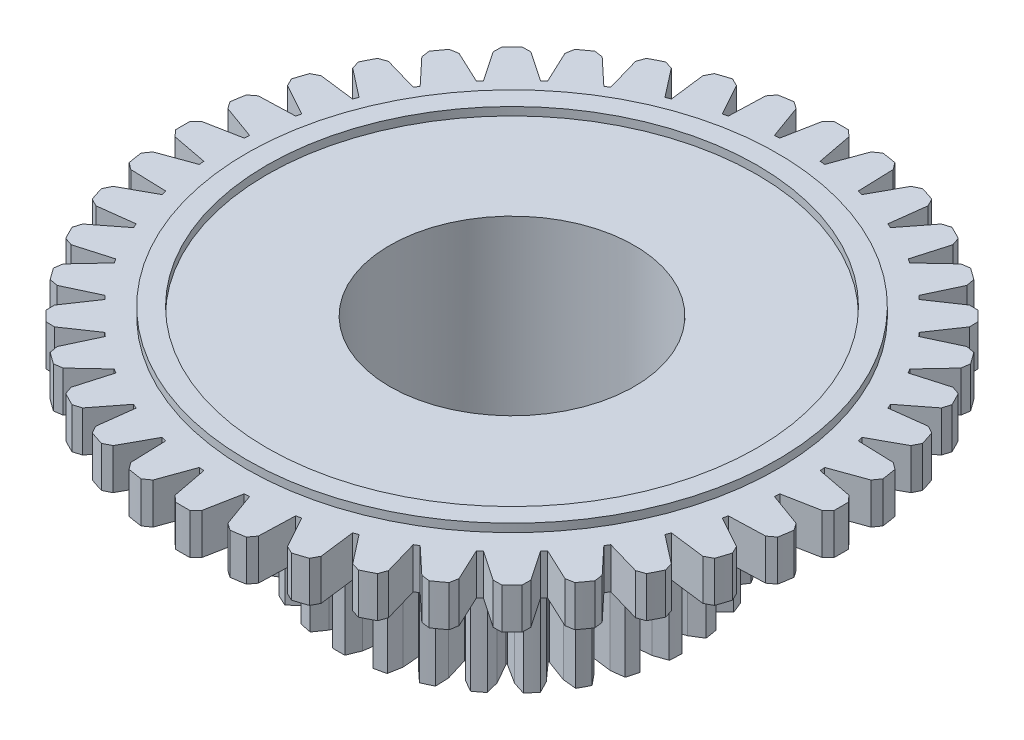
from build123d import *

# Parameters (mm, degrees)
BOSS_EXTRUDE1_DEPTH = 1
SKETCH2_R           = 6.500405198
SKETCH2_R_2         = 6.000405198
BOSS_EXTRUDE2_DEPTH = 0.2
SKETCH4_R           = 2.995
CUT_EXTRUDE3_DEPTH  = 4.2
SKETCH6_R           = 2.995
BOSS_EXTRUDE4_DEPTH = 4


with BuildPart() as part:
    # Sketch1 → Boss-Extrude1 (new body)
    with BuildSketch(Plane(origin=(0, 0, 0), x_dir=(1, 0, 0), z_dir=(0, 1, 0))):
        with BuildLine():
            Line((-0.176242376, 8.068075274), (-0.326242376, 7.922481316))
            Line((-0.326242376, 7.922481316), (-0.493178269, 7.052777835))
            ThreePointArc((-0.493178269, 7.052777835), (-0.554705807, 7.048205549), (-0.616191101, 7.043096516))
            Line((-0.616191101, 7.043096516), (-0.917123335, 7.875977976))
            Line((-0.917123335, 7.875977976), (-1.088052499, 7.996314261))
            ThreePointArc((-1.088052499, 7.996314261), (-1.262426133, 7.970644909), (-1.43619758, 7.941173497))
            Line((-1.43619758, 7.941173497), (-1.561574918, 7.773906872))
            Line((-1.561574918, 7.773906872), (-1.590403954, 6.888796358))
            ThreePointArc((-1.590403954, 6.888796358), (-1.650458722, 6.874655337), (-1.710387802, 6.859990785))
            Line((-1.710387802, 6.859990785), (-2.137906426, 7.635541919))
            Line((-2.137906426, 7.635541919), (-2.325555911, 7.727657453))
            ThreePointArc((-2.325555911, 7.727657453), (-2.493767145, 7.675026087), (-2.660788832, 7.618733674))
            Line((-2.660788832, 7.618733674), (-2.758456302, 7.433913042))
            Line((-2.758456302, 7.433913042), (-2.648468615, 6.555189852))
            ThreePointArc((-2.648468615, 6.555189852), (-2.705571867, 6.531828295), (-2.762469078, 6.507969314))
            Line((-2.762469078, 6.507969314), (-3.306047166, 7.207093479))
            Line((-3.306047166, 7.207093479), (-3.505796418, 7.268720071))
            ThreePointArc((-3.505796418, 7.268720071), (-3.663703333, 7.19042265), (-3.819862633, 7.108695342))
            Line((-3.819862633, 7.108695342), (-3.887415337, 6.910871601))
            Line((-3.887415337, 6.910871601), (-3.64131919, 6.060172816))
            ThreePointArc((-3.64131919, 6.060172816), (-3.694064853, 6.028165962), (-3.746529198, 5.99570004))
            Line((-3.746529198, 5.99570004), (-4.392782052, 6.601182479))
            Line((-4.392782052, 6.601182479), (-4.599712583, 6.630802678))
            ThreePointArc((-4.599712583, 6.630802678), (-4.743426986, 6.528767145), (-4.884878738, 6.423617339))
            Line((-4.884878738, 6.423617339), (-4.920653306, 6.217661565))
            Line((-4.920653306, 6.217661565), (-4.5445084, 5.415934213))
            ThreePointArc((-4.5445084, 5.415934213), (-4.591597702, 5.376070177), (-4.638337335, 5.335796732))
            Line((-4.638337335, 5.335796732), (-5.371352066, 5.832728459))
            Line((-5.371352066, 5.832728459), (-5.580368558, 5.829612917))
            ThreePointArc((-5.580368558, 5.829612917), (-5.706351724, 5.706351724), (-5.829612917, 5.580368558))
            Line((-5.829612917, 5.580368558), (-5.832728459, 5.371352066))
            Line((-5.832728459, 5.371352066), (-5.335796732, 4.638337335))
            ThreePointArc((-5.335796732, 4.638337335), (-5.376070177, 4.591597702), (-5.415934213, 4.5445084))
            Line((-5.415934213, 4.5445084), (-6.217661565, 4.920653306))
            Line((-6.217661565, 4.920653306), (-6.423617339, 4.884878738))
            ThreePointArc((-6.423617339, 4.884878738), (-6.528767145, 4.743426986), (-6.630802678, 4.599712583))
            Line((-6.630802678, 4.599712583), (-6.601182479, 4.392782052))
            Line((-6.601182479, 4.392782052), (-5.99570004, 3.746529198))
            ThreePointArc((-5.99570004, 3.746529198), (-6.028165962, 3.694064853), (-6.060172816, 3.64131919))
            Line((-6.060172816, 3.64131919), (-6.910871601, 3.887415337))
            Line((-6.910871601, 3.887415337), (-7.108695342, 3.819862633))
            ThreePointArc((-7.108695342, 3.819862633), (-7.19042265, 3.663703333), (-7.268720071, 3.505796418))
            Line((-7.268720071, 3.505796418), (-7.207093479, 3.306047166))
            Line((-7.207093479, 3.306047166), (-6.507969314, 2.762469078))
            ThreePointArc((-6.507969314, 2.762469078), (-6.531828295, 2.705571867), (-6.555189852, 2.648468615))
            Line((-6.555189852, 2.648468615), (-7.433913042, 2.758456302))
            Line((-7.433913042, 2.758456302), (-7.618733674, 2.660788832))
            ThreePointArc((-7.618733674, 2.660788832), (-7.675026087, 2.493767145), (-7.727657453, 2.325555911))
            Line((-7.727657453, 2.325555911), (-7.635541919, 2.137906426))
            Line((-7.635541919, 2.137906426), (-6.859990785, 1.710387802))
            ThreePointArc((-6.859990785, 1.710387802), (-6.874655337, 1.650458722), (-6.888796358, 1.590403954))
            Line((-6.888796358, 1.590403954), (-7.773906872, 1.561574918))
            Line((-7.773906872, 1.561574918), (-7.941173497, 1.43619758))
            ThreePointArc((-7.941173497, 1.43619758), (-7.970644909, 1.262426133), (-7.996314261, 1.088052499))
            Line((-7.996314261, 1.088052499), (-7.875977976, 0.917123335))
            Line((-7.875977976, 0.917123335), (-7.043096516, 0.616191101))
            ThreePointArc((-7.043096516, 0.616191101), (-7.048205549, 0.554705807), (-7.052777835, 0.493178269))
            Line((-7.052777835, 0.493178269), (-7.922481316, 0.326242376))
            Line((-7.922481316, 0.326242376), (-8.068075274, 0.176242376))
            ThreePointArc((-8.068075274, 0.176242376), (-8.07, 0), (-8.068075274, -0.176242376))
            Line((-8.068075274, -0.176242376), (-7.922481316, -0.326242376))
            Line((-7.922481316, -0.326242376), (-7.052777835, -0.493178269))
            ThreePointArc((-7.052777835, -0.493178269), (-7.048205549, -0.554705807), (-7.043096516, -0.616191101))
            Line((-7.043096516, -0.616191101), (-7.875977976, -0.917123335))
            Line((-7.875977976, -0.917123335), (-7.996314261, -1.088052499))
            ThreePointArc((-7.996314261, -1.088052499), (-7.970644909, -1.262426133), (-7.941173497, -1.43619758))
            Line((-7.941173497, -1.43619758), (-7.773906872, -1.561574918))
            Line((-7.773906872, -1.561574918), (-6.888796358, -1.590403954))
            ThreePointArc((-6.888796358, -1.590403954), (-6.874655337, -1.650458722), (-6.859990785, -1.710387802))
            Line((-6.859990785, -1.710387802), (-7.635541919, -2.137906426))
            Line((-7.635541919, -2.137906426), (-7.727657453, -2.325555911))
            ThreePointArc((-7.727657453, -2.325555911), (-7.675026087, -2.493767145), (-7.618733674, -2.660788832))
            Line((-7.618733674, -2.660788832), (-7.433913042, -2.758456302))
            Line((-7.433913042, -2.758456302), (-6.555189852, -2.648468615))
            ThreePointArc((-6.555189852, -2.648468615), (-6.531828295, -2.705571867), (-6.507969314, -2.762469078))
            Line((-6.507969314, -2.762469078), (-7.207093479, -3.306047166))
            Line((-7.207093479, -3.306047166), (-7.268720071, -3.505796418))
            ThreePointArc((-7.268720071, -3.505796418), (-7.19042265, -3.663703333), (-7.108695342, -3.819862633))
            Line((-7.108695342, -3.819862633), (-6.910871601, -3.887415337))
            Line((-6.910871601, -3.887415337), (-6.060172816, -3.64131919))
            ThreePointArc((-6.060172816, -3.64131919), (-6.028165962, -3.694064853), (-5.99570004, -3.746529198))
            Line((-5.99570004, -3.746529198), (-6.601182479, -4.392782052))
            Line((-6.601182479, -4.392782052), (-6.630802678, -4.599712583))
            ThreePointArc((-6.630802678, -4.599712583), (-6.528767145, -4.743426986), (-6.423617339, -4.884878738))
            Line((-6.423617339, -4.884878738), (-6.217661565, -4.920653306))
            Line((-6.217661565, -4.920653306), (-5.415934213, -4.5445084))
            ThreePointArc((-5.415934213, -4.5445084), (-5.376070177, -4.591597702), (-5.335796732, -4.638337335))
            Line((-5.335796732, -4.638337335), (-5.832728459, -5.371352066))
            Line((-5.832728459, -5.371352066), (-5.829612917, -5.580368558))
            ThreePointArc((-5.829612917, -5.580368558), (-5.706351724, -5.706351724), (-5.580368558, -5.829612917))
            Line((-5.580368558, -5.829612917), (-5.371352066, -5.832728459))
            Line((-5.371352066, -5.832728459), (-4.638337335, -5.335796732))
            ThreePointArc((-4.638337335, -5.335796732), (-4.591597702, -5.376070177), (-4.5445084, -5.415934213))
            Line((-4.5445084, -5.415934213), (-4.920653306, -6.217661565))
            Line((-4.920653306, -6.217661565), (-4.884878738, -6.423617339))
            ThreePointArc((-4.884878738, -6.423617339), (-4.743426986, -6.528767145), (-4.599712583, -6.630802678))
            Line((-4.599712583, -6.630802678), (-4.392782052, -6.601182479))
            Line((-4.392782052, -6.601182479), (-3.746529198, -5.99570004))
            ThreePointArc((-3.746529198, -5.99570004), (-3.694064853, -6.028165962), (-3.64131919, -6.060172816))
            Line((-3.64131919, -6.060172816), (-3.887415337, -6.910871601))
            Line((-3.887415337, -6.910871601), (-3.819862633, -7.108695342))
            ThreePointArc((-3.819862633, -7.108695342), (-3.663703333, -7.19042265), (-3.505796418, -7.268720071))
            Line((-3.505796418, -7.268720071), (-3.306047166, -7.207093479))
            Line((-3.306047166, -7.207093479), (-2.762469078, -6.507969314))
            ThreePointArc((-2.762469078, -6.507969314), (-2.705571867, -6.531828295), (-2.648468615, -6.555189852))
            Line((-2.648468615, -6.555189852), (-2.758456302, -7.433913042))
            Line((-2.758456302, -7.433913042), (-2.660788832, -7.618733674))
            ThreePointArc((-2.660788832, -7.618733674), (-2.493767145, -7.675026087), (-2.325555911, -7.727657453))
            Line((-2.325555911, -7.727657453), (-2.137906426, -7.635541919))
            Line((-2.137906426, -7.635541919), (-1.710387802, -6.859990785))
            ThreePointArc((-1.710387802, -6.859990785), (-1.650458722, -6.874655337), (-1.590403954, -6.888796358))
            Line((-1.590403954, -6.888796358), (-1.561574918, -7.773906872))
            Line((-1.561574918, -7.773906872), (-1.43619758, -7.941173497))
            ThreePointArc((-1.43619758, -7.941173497), (-1.262426133, -7.970644909), (-1.088052499, -7.996314261))
            Line((-1.088052499, -7.996314261), (-0.917123335, -7.875977976))
            Line((-0.917123335, -7.875977976), (-0.616191101, -7.043096516))
            ThreePointArc((-0.616191101, -7.043096516), (-0.554705807, -7.048205549), (-0.493178269, -7.052777835))
            Line((-0.493178269, -7.052777835), (-0.326242376, -7.922481316))
            Line((-0.326242376, -7.922481316), (-0.176242376, -8.068075274))
            ThreePointArc((-0.176242376, -8.068075274), (0, -8.07), (0.176242376, -8.068075274))
            Line((0.176242376, -8.068075274), (0.326242376, -7.922481316))
            Line((0.326242376, -7.922481316), (0.493178269, -7.052777835))
            ThreePointArc((0.493178269, -7.052777835), (0.554705807, -7.048205549), (0.616191101, -7.043096516))
            Line((0.616191101, -7.043096516), (0.917123335, -7.875977976))
            Line((0.917123335, -7.875977976), (1.088052499, -7.996314261))
            ThreePointArc((1.088052499, -7.996314261), (1.262426133, -7.970644909), (1.43619758, -7.941173497))
            Line((1.43619758, -7.941173497), (1.561574918, -7.773906872))
            Line((1.561574918, -7.773906872), (1.590403954, -6.888796358))
            ThreePointArc((1.590403954, -6.888796358), (1.650458722, -6.874655337), (1.710387802, -6.859990785))
            Line((1.710387802, -6.859990785), (2.137906426, -7.635541919))
            Line((2.137906426, -7.635541919), (2.325555911, -7.727657453))
            ThreePointArc((2.325555911, -7.727657453), (2.493767145, -7.675026087), (2.660788832, -7.618733674))
            Line((2.660788832, -7.618733674), (2.758456302, -7.433913042))
            Line((2.758456302, -7.433913042), (2.648468615, -6.555189852))
            ThreePointArc((2.648468615, -6.555189852), (2.705571867, -6.531828295), (2.762469078, -6.507969314))
            Line((2.762469078, -6.507969314), (3.306047166, -7.207093479))
            Line((3.306047166, -7.207093479), (3.505796418, -7.268720071))
            ThreePointArc((3.505796418, -7.268720071), (3.663703333, -7.19042265), (3.819862633, -7.108695342))
            Line((3.819862633, -7.108695342), (3.887415337, -6.910871601))
            Line((3.887415337, -6.910871601), (3.64131919, -6.060172816))
            ThreePointArc((3.64131919, -6.060172816), (3.694064853, -6.028165962), (3.746529198, -5.99570004))
            Line((3.746529198, -5.99570004), (4.392782052, -6.601182479))
            Line((4.392782052, -6.601182479), (4.599712583, -6.630802678))
            ThreePointArc((4.599712583, -6.630802678), (4.743426986, -6.528767145), (4.884878738, -6.423617339))
            Line((4.884878738, -6.423617339), (4.920653306, -6.217661565))
            Line((4.920653306, -6.217661565), (4.5445084, -5.415934213))
            ThreePointArc((4.5445084, -5.415934213), (4.591597702, -5.376070177), (4.638337335, -5.335796732))
            Line((4.638337335, -5.335796732), (5.371352066, -5.832728459))
            Line((5.371352066, -5.832728459), (5.580368558, -5.829612917))
            ThreePointArc((5.580368558, -5.829612917), (5.706351724, -5.706351724), (5.829612917, -5.580368558))
            Line((5.829612917, -5.580368558), (5.832728459, -5.371352066))
            Line((5.832728459, -5.371352066), (5.335796732, -4.638337335))
            ThreePointArc((5.335796732, -4.638337335), (5.376070177, -4.591597702), (5.415934213, -4.5445084))
            Line((5.415934213, -4.5445084), (6.217661565, -4.920653306))
            Line((6.217661565, -4.920653306), (6.423617339, -4.884878738))
            ThreePointArc((6.423617339, -4.884878738), (6.528767145, -4.743426986), (6.630802678, -4.599712583))
            Line((6.630802678, -4.599712583), (6.601182479, -4.392782052))
            Line((6.601182479, -4.392782052), (5.99570004, -3.746529198))
            ThreePointArc((5.99570004, -3.746529198), (6.028165962, -3.694064853), (6.060172816, -3.64131919))
            Line((6.060172816, -3.64131919), (6.910871601, -3.887415337))
            Line((6.910871601, -3.887415337), (7.108695342, -3.819862633))
            ThreePointArc((7.108695342, -3.819862633), (7.19042265, -3.663703333), (7.268720071, -3.505796418))
            Line((7.268720071, -3.505796418), (7.207093479, -3.306047166))
            Line((7.207093479, -3.306047166), (6.507969314, -2.762469078))
            ThreePointArc((6.507969314, -2.762469078), (6.531828295, -2.705571867), (6.555189852, -2.648468615))
            Line((6.555189852, -2.648468615), (7.433913042, -2.758456302))
            Line((7.433913042, -2.758456302), (7.618733674, -2.660788832))
            ThreePointArc((7.618733674, -2.660788832), (7.675026087, -2.493767145), (7.727657453, -2.325555911))
            Line((7.727657453, -2.325555911), (7.635541919, -2.137906426))
            Line((7.635541919, -2.137906426), (6.859990785, -1.710387802))
            ThreePointArc((6.859990785, -1.710387802), (6.874655337, -1.650458722), (6.888796358, -1.590403954))
            Line((6.888796358, -1.590403954), (7.773906872, -1.561574918))
            Line((7.773906872, -1.561574918), (7.941173497, -1.43619758))
            ThreePointArc((7.941173497, -1.43619758), (7.970644909, -1.262426133), (7.996314261, -1.088052499))
            Line((7.996314261, -1.088052499), (7.875977976, -0.917123335))
            Line((7.875977976, -0.917123335), (7.043096516, -0.616191101))
            ThreePointArc((7.043096516, -0.616191101), (7.048205549, -0.554705807), (7.052777835, -0.493178269))
            Line((7.052777835, -0.493178269), (7.922481316, -0.326242376))
            Line((7.922481316, -0.326242376), (8.068075274, -0.176242376))
            ThreePointArc((8.068075274, -0.176242376), (8.07, 0), (8.068075274, 0.176242376))
            Line((8.068075274, 0.176242376), (7.922481316, 0.326242376))
            Line((7.922481316, 0.326242376), (7.052777835, 0.493178269))
            ThreePointArc((7.052777835, 0.493178269), (7.048205549, 0.554705807), (7.043096516, 0.616191101))
            Line((7.043096516, 0.616191101), (7.875977976, 0.917123335))
            Line((7.875977976, 0.917123335), (7.996314261, 1.088052499))
            ThreePointArc((7.996314261, 1.088052499), (7.970644909, 1.262426133), (7.941173497, 1.43619758))
            Line((7.941173497, 1.43619758), (7.773906872, 1.561574918))
            Line((7.773906872, 1.561574918), (6.888796358, 1.590403954))
            ThreePointArc((6.888796358, 1.590403954), (6.874655337, 1.650458722), (6.859990785, 1.710387802))
            Line((6.859990785, 1.710387802), (7.635541919, 2.137906426))
            Line((7.635541919, 2.137906426), (7.727657453, 2.325555911))
            ThreePointArc((7.727657453, 2.325555911), (7.675026087, 2.493767145), (7.618733674, 2.660788832))
            Line((7.618733674, 2.660788832), (7.433913042, 2.758456302))
            Line((7.433913042, 2.758456302), (6.555189852, 2.648468615))
            ThreePointArc((6.555189852, 2.648468615), (6.531828295, 2.705571867), (6.507969314, 2.762469078))
            Line((6.507969314, 2.762469078), (7.207093479, 3.306047166))
            Line((7.207093479, 3.306047166), (7.268720071, 3.505796418))
            ThreePointArc((7.268720071, 3.505796418), (7.19042265, 3.663703333), (7.108695342, 3.819862633))
            Line((7.108695342, 3.819862633), (6.910871601, 3.887415337))
            Line((6.910871601, 3.887415337), (6.060172816, 3.64131919))
            ThreePointArc((6.060172816, 3.64131919), (6.028165962, 3.694064853), (5.99570004, 3.746529198))
            Line((5.99570004, 3.746529198), (6.601182479, 4.392782052))
            Line((6.601182479, 4.392782052), (6.630802678, 4.599712583))
            ThreePointArc((6.630802678, 4.599712583), (6.528767145, 4.743426986), (6.423617339, 4.884878738))
            Line((6.423617339, 4.884878738), (6.217661565, 4.920653306))
            Line((6.217661565, 4.920653306), (5.415934213, 4.5445084))
            ThreePointArc((5.415934213, 4.5445084), (5.376070177, 4.591597702), (5.335796732, 4.638337335))
            Line((5.335796732, 4.638337335), (5.832728459, 5.371352066))
            Line((5.832728459, 5.371352066), (5.829612917, 5.580368558))
            ThreePointArc((5.829612917, 5.580368558), (5.706351724, 5.706351724), (5.580368558, 5.829612917))
            Line((5.580368558, 5.829612917), (5.371352066, 5.832728459))
            Line((5.371352066, 5.832728459), (4.638337335, 5.335796732))
            ThreePointArc((4.638337335, 5.335796732), (4.591597702, 5.376070177), (4.5445084, 5.415934213))
            Line((4.5445084, 5.415934213), (4.920653306, 6.217661565))
            Line((4.920653306, 6.217661565), (4.884878738, 6.423617339))
            ThreePointArc((4.884878738, 6.423617339), (4.743426986, 6.528767145), (4.599712583, 6.630802678))
            Line((4.599712583, 6.630802678), (4.392782052, 6.601182479))
            Line((4.392782052, 6.601182479), (3.746529198, 5.99570004))
            ThreePointArc((3.746529198, 5.99570004), (3.694064853, 6.028165962), (3.64131919, 6.060172816))
            Line((3.64131919, 6.060172816), (3.887415337, 6.910871601))
            Line((3.887415337, 6.910871601), (3.819862633, 7.108695342))
            ThreePointArc((3.819862633, 7.108695342), (3.663703333, 7.19042265), (3.505796418, 7.268720071))
            Line((3.505796418, 7.268720071), (3.306047166, 7.207093479))
            Line((3.306047166, 7.207093479), (2.762469078, 6.507969314))
            ThreePointArc((2.762469078, 6.507969314), (2.705571867, 6.531828295), (2.648468615, 6.555189852))
            Line((2.648468615, 6.555189852), (2.758456302, 7.433913042))
            Line((2.758456302, 7.433913042), (2.660788832, 7.618733674))
            ThreePointArc((2.660788832, 7.618733674), (2.493767145, 7.675026087), (2.325555911, 7.727657453))
            Line((2.325555911, 7.727657453), (2.137906426, 7.635541919))
            Line((2.137906426, 7.635541919), (1.710387802, 6.859990785))
            ThreePointArc((1.710387802, 6.859990785), (1.650458722, 6.874655337), (1.590403954, 6.888796358))
            Line((1.590403954, 6.888796358), (1.561574918, 7.773906872))
            Line((1.561574918, 7.773906872), (1.43619758, 7.941173497))
            ThreePointArc((1.43619758, 7.941173497), (1.262426133, 7.970644909), (1.088052499, 7.996314261))
            Line((1.088052499, 7.996314261), (0.917123335, 7.875977976))
            Line((0.917123335, 7.875977976), (0.616191101, 7.043096516))
            ThreePointArc((0.616191101, 7.043096516), (0.554705807, 7.048205549), (0.493178269, 7.052777835))
            Line((0.493178269, 7.052777835), (0.326242376, 7.922481316))
            Line((0.326242376, 7.922481316), (0.176242376, 8.068075274))
            ThreePointArc((0.176242376, 8.068075274), (0, 8.07), (-0.176242376, 8.068075274))
        make_face()
    extrude(amount=BOSS_EXTRUDE1_DEPTH)

    # Sketch2 → Boss-Extrude2 (add)
    with BuildSketch(Plane(origin=(0, 1, 0), x_dir=(1, 0, 0), z_dir=(0, 1, 0))):
        Circle(SKETCH2_R)
        Circle(SKETCH2_R_2, mode=Mode.SUBTRACT)
    extrude(amount=BOSS_EXTRUDE2_DEPTH)

    # Sketch4 → Cut-Extrude3 (cut)
    with BuildSketch(Plane(origin=(0, 1, 0), x_dir=(1, 0, 0), z_dir=(0, 1, 0))):
        Circle(SKETCH4_R)
    extrude(amount=-CUT_EXTRUDE3_DEPTH, mode=Mode.SUBTRACT)

    # Sketch6 → Boss-Extrude4 (add)
    with BuildSketch(Plane.XZ):
        with BuildLine():
            Line((0.148148364, 4.242414061), (0.275189289, 3.935390178))
            Line((0.275189289, 3.935390178), (0.354610282, 3.357133897))
            ThreePointArc((0.354610282, 3.357133897), (0.364989316, 3.356021343), (0.375364861, 3.354876701))
            Line((0.375364861, 3.354876701), (0.577237043, 3.902540505))
            Line((0.577237043, 3.902540505), (0.767308881, 4.175076296))
            ThreePointArc((0.767308881, 4.175076296), (0.912549519, 4.145754259), (1.056678355, 4.111381259))
            Line((1.056678355, 4.111381259), (1.114748075, 3.78422538))
            Line((1.114748075, 3.78422538), (1.068004243, 3.202415244))
            ThreePointArc((1.068004243, 3.202415244), (1.077901455, 3.199097515), (1.08778836, 3.195749198))
            Line((1.08778836, 3.195749198), (1.402672412, 3.687212376))
            Line((1.402672412, 3.687212376), (1.646887615, 3.912516605))
            ThreePointArc((1.646887615, 3.912516605), (1.782429236, 3.852657657), (1.915799242, 3.788104838))
            Line((1.915799242, 3.788104838), (1.902182481, 3.456114409))
            Line((1.902182481, 3.456114409), (1.731459512, 2.897955213))
            ThreePointArc((1.731459512, 2.897955213), (1.740412119, 2.892587443), (1.749348085, 2.887192015))
            Line((1.749348085, 2.887192015), (2.162520378, 3.299474294))
            Line((2.162520378, 3.299474294), (2.449459715, 3.467011985))
            ThreePointArc((2.449459715, 3.467011985), (2.568964543, 3.379415064), (2.685339485, 3.287700846))
            Line((2.685339485, 3.287700846), (2.600672947, 2.96639937))
            Line((2.600672947, 2.96639937), (2.313953658, 2.457990017))
            ThreePointArc((2.313953658, 2.457990017), (2.321543046, 2.450823196), (2.329110237, 2.443632943))
            Line((2.329110237, 2.443632943), (2.821251295, 2.757456461))
            Line((2.821251295, 2.757456461), (3.137497801, 2.859393738))
            ThreePointArc((3.137497801, 2.859393738), (3.235377924, 2.748154779), (3.329316238, 2.633567616))
            Line((3.329316238, 2.633567616), (3.177558837, 2.337978793))
            Line((3.177558837, 2.337978793), (2.788249904, 1.90309194))
            ThreePointArc((2.788249904, 1.90309194), (2.794121201, 1.894461181), (2.799965784, 1.885812309))
            Line((2.799965784, 1.885812309), (3.348063636, 2.086503028))
            Line((3.348063636, 2.086503028), (3.678829976, 2.118073418))
            ThreePointArc((3.678829976, 2.118073418), (3.750508629, 1.988393831), (3.817617864, 1.856291691))
            Line((3.817617864, 1.856291691), (3.605865608, 1.600236926))
            Line((3.605865608, 1.600236926), (3.132170682, 1.259207399))
            ThreePointArc((3.132170682, 1.259207399), (3.136049355, 1.249516267), (3.139898042, 1.239813189))
            Line((3.139898042, 1.239813189), (3.718324244, 1.317987033))
            Line((3.718324244, 1.317987033), (4.048144151, 1.27771434))
            ThreePointArc((4.048144151, 1.27771434), (4.090269718, 1.135657797), (4.127411922, 0.99221763))
            Line((4.127411922, 0.99221763), (3.86556611, 0.787669759))
            Line((3.86556611, 0.787669759), (3.329634641, 0.556443719))
            ThreePointArc((3.329634641, 0.556443719), (3.331339325, 0.546145361), (3.333012157, 0.535841781))
            Line((3.333012157, 0.535841781), (3.914720142, 0.487843429))
            Line((3.914720142, 0.487843429), (4.228171604, 0.377610758))
            ThreePointArc((4.228171604, 0.377610758), (4.238774342, 0.229819667), (4.244212786, 0.081748576))
            Line((4.244212786, 0.081748576), (3.944517037, -0.061727971))
            Line((3.944517037, -0.061727971), (3.371408585, -0.172338651))
            ThreePointArc((3.371408585, -0.172338651), (3.370859572, -0.182762695), (3.370278329, -0.193184993))
            Line((3.370278329, -0.193184993), (3.928068077, -0.365111191))
            Line((3.928068077, -0.365111191), (4.210494453, -0.540149483))
            ThreePointArc((4.210494453, -0.540149483), (4.189078588, -0.686764575), (4.162558977, -0.832542951))
            Line((4.162558977, -0.832542951), (3.839026732, -0.908239369))
            Line((3.839026732, -0.908239369), (3.25553921, -0.893062656))
            ThreePointArc((3.25553921, -0.893062656), (3.252762171, -0.903124971), (3.249954032, -0.913178651))
            Line((3.249954032, -0.913178651), (3.757743915, -1.200993618))
            Line((3.757743915, -1.200993618), (3.99593926, -1.432652934))
            ThreePointArc((3.99593926, -1.432652934), (3.943506176, -1.571236469), (3.886268536, -1.707905695))
            Line((3.886268536, -1.707905695), (3.554027803, -1.712282504))
            Line((3.554027803, -1.712282504), (2.98744444, -1.572028045))
            ThreePointArc((2.98744444, -1.572028045), (2.982569227, -1.581258127), (2.977665496, -1.590473091))
            Line((2.977665496, -1.590473091), (3.411711823, -1.980718918))
            Line((3.411711823, -1.980718918), (3.594538389, -2.258167126))
            ThreePointArc((3.594538389, -2.258167126), (3.513539797, -2.382239092), (3.428260498, -2.503408667))
            Line((3.428260498, -2.503408667), (3.102846485, -2.436261212))
            Line((3.102846485, -2.436261212), (2.579660088, -2.177487149))
            ThreePointArc((2.579660088, -2.177487149), (2.57291466, -2.18545341), (2.566144631, -2.193398776))
            Line((2.566144631, -2.193398776), (2.906151879, -2.667828003))
            Line((2.906151879, -2.667828003), (3.025060898, -2.978091934))
            ThreePointArc((3.025060898, -2.978091934), (2.919284203, -3.081850863), (2.80995081, -3.181855032))
            Line((2.80995081, -3.181855032), (2.506579513, -3.046323053))
            Line((2.506579513, -3.046323053), (2.051253698, -2.681129374))
            ThreePointArc((2.051253698, -2.681129374), (2.042953463, -2.687459321), (2.034633695, -2.693763572))
            Line((2.034633695, -2.693763572), (2.264703503, -3.230192416))
            Line((2.264703503, -3.230192416), (2.314134921, -3.558764472))
            ThreePointArc((2.314134921, -3.558764472), (2.188526124, -3.637358713), (2.060250944, -3.711521392))
            Line((2.060250944, -3.711521392), (1.793107669, -3.513942215))
            Line((1.793107669, -3.513942215), (1.426932965, -3.05940497))
            ThreePointArc((1.426932965, -3.05940497), (1.417466033, -3.063802621), (1.407985549, -3.068170978))
            Line((1.407985549, -3.068170978), (1.517360108, -3.641516621))
            Line((1.517360108, -3.641516621), (1.495002568, -3.973033139))
            ThreePointArc((1.495002568, -3.973033139), (1.355434995, -4.022787712), (1.214216035, -4.067641137))
            Line((1.214216035, -4.067641137), (0.995792103, -3.817253343))
            Line((0.995792103, -3.817253343), (0.735890432, -3.294626189))
            ThreePointArc((0.735890432, -3.294626189), (0.725699467, -3.296885915), (0.715501563, -3.299114119))
            Line((0.715501563, -3.299114119), (0.699066641, -3.882567557))
            Line((0.699066641, -3.882567557), (0.605965555, -4.201527192))
            ThreePointArc((0.605965555, -4.201527192), (0.458965233, -4.220115628), (0.311405733, -4.233562503))
            Line((0.311405733, -4.233562503), (0.151914406, -3.942073948))
            Line((0.151914406, -3.942073948), (0.01043848, -3.37579435))
            ThreePointArc((0.01043848, -3.37579435), (0, -3.375810489), (-0.01043848, -3.37579435))
            Line((-0.01043848, -3.37579435), (-0.151914406, -3.942073948))
            Line((-0.151914406, -3.942073948), (-0.311405733, -4.233562503))
            ThreePointArc((-0.311405733, -4.233562503), (-0.458965233, -4.220115628), (-0.605965555, -4.201527192))
            Line((-0.605965555, -4.201527192), (-0.699066641, -3.882567557))
            Line((-0.699066641, -3.882567557), (-0.715501563, -3.299114119))
            ThreePointArc((-0.715501563, -3.299114119), (-0.725699467, -3.296885915), (-0.735890432, -3.294626189))
            Line((-0.735890432, -3.294626189), (-0.995792103, -3.817253343))
            Line((-0.995792103, -3.817253343), (-1.214216035, -4.067641137))
            ThreePointArc((-1.214216035, -4.067641137), (-1.355434995, -4.022787712), (-1.495002568, -3.973033139))
            Line((-1.495002568, -3.973033139), (-1.517360108, -3.641516621))
            Line((-1.517360108, -3.641516621), (-1.407985549, -3.068170978))
            ThreePointArc((-1.407985549, -3.068170978), (-1.417466033, -3.063802621), (-1.426932965, -3.05940497))
            Line((-1.426932965, -3.05940497), (-1.793107669, -3.513942215))
            Line((-1.793107669, -3.513942215), (-2.060250944, -3.711521392))
            ThreePointArc((-2.060250944, -3.711521392), (-2.188526124, -3.637358713), (-2.314134921, -3.558764472))
            Line((-2.314134921, -3.558764472), (-2.264703503, -3.230192416))
            Line((-2.264703503, -3.230192416), (-2.034633695, -2.693763572))
            ThreePointArc((-2.034633695, -2.693763572), (-2.042953463, -2.687459321), (-2.051253698, -2.681129374))
            Line((-2.051253698, -2.681129374), (-2.506579513, -3.046323053))
            Line((-2.506579513, -3.046323053), (-2.80995081, -3.181855032))
            ThreePointArc((-2.80995081, -3.181855032), (-2.919284203, -3.081850863), (-3.025060898, -2.978091934))
            Line((-3.025060898, -2.978091934), (-2.906151879, -2.667828003))
            Line((-2.906151879, -2.667828003), (-2.566144631, -2.193398776))
            ThreePointArc((-2.566144631, -2.193398776), (-2.57291466, -2.18545341), (-2.579660088, -2.177487149))
            Line((-2.579660088, -2.177487149), (-3.102846485, -2.436261212))
            Line((-3.102846485, -2.436261212), (-3.428260498, -2.503408667))
            ThreePointArc((-3.428260498, -2.503408667), (-3.513539797, -2.382239092), (-3.594538389, -2.258167126))
            Line((-3.594538389, -2.258167126), (-3.411711823, -1.980718918))
            Line((-3.411711823, -1.980718918), (-2.977665496, -1.590473091))
            ThreePointArc((-2.977665496, -1.590473091), (-2.982569227, -1.581258127), (-2.98744444, -1.572028045))
            Line((-2.98744444, -1.572028045), (-3.554027803, -1.712282504))
            Line((-3.554027803, -1.712282504), (-3.886268536, -1.707905695))
            ThreePointArc((-3.886268536, -1.707905695), (-3.943506176, -1.571236469), (-3.99593926, -1.432652934))
            Line((-3.99593926, -1.432652934), (-3.757743915, -1.200993618))
            Line((-3.757743915, -1.200993618), (-3.249954032, -0.913178651))
            ThreePointArc((-3.249954032, -0.913178651), (-3.252762171, -0.903124971), (-3.25553921, -0.893062656))
            Line((-3.25553921, -0.893062656), (-3.839026732, -0.908239369))
            Line((-3.839026732, -0.908239369), (-4.162558977, -0.832542951))
            ThreePointArc((-4.162558977, -0.832542951), (-4.189078588, -0.686764575), (-4.210494453, -0.540149483))
            Line((-4.210494453, -0.540149483), (-3.928068077, -0.365111191))
            Line((-3.928068077, -0.365111191), (-3.370278329, -0.193184993))
            ThreePointArc((-3.370278329, -0.193184993), (-3.370859572, -0.182762695), (-3.371408585, -0.172338651))
            Line((-3.371408585, -0.172338651), (-3.944517037, -0.061727971))
            Line((-3.944517037, -0.061727971), (-4.244212786, 0.081748576))
            ThreePointArc((-4.244212786, 0.081748576), (-4.238774342, 0.229819667), (-4.228171604, 0.377610758))
            Line((-4.228171604, 0.377610758), (-3.914720142, 0.487843429))
            Line((-3.914720142, 0.487843429), (-3.333012157, 0.535841781))
            ThreePointArc((-3.333012157, 0.535841781), (-3.331339325, 0.546145361), (-3.329634641, 0.556443719))
            Line((-3.329634641, 0.556443719), (-3.86556611, 0.787669759))
            Line((-3.86556611, 0.787669759), (-4.127411922, 0.99221763))
            ThreePointArc((-4.127411922, 0.99221763), (-4.090269718, 1.135657797), (-4.048144151, 1.27771434))
            Line((-4.048144151, 1.27771434), (-3.718324244, 1.317987033))
            Line((-3.718324244, 1.317987033), (-3.139898042, 1.239813189))
            ThreePointArc((-3.139898042, 1.239813189), (-3.136049355, 1.249516267), (-3.132170682, 1.259207399))
            Line((-3.132170682, 1.259207399), (-3.605865608, 1.600236926))
            Line((-3.605865608, 1.600236926), (-3.817617864, 1.856291691))
            ThreePointArc((-3.817617864, 1.856291691), (-3.750508629, 1.988393831), (-3.678829976, 2.118073418))
            Line((-3.678829976, 2.118073418), (-3.348063636, 2.086503028))
            Line((-3.348063636, 2.086503028), (-2.799965784, 1.885812309))
            ThreePointArc((-2.799965784, 1.885812309), (-2.794121201, 1.894461181), (-2.788249904, 1.90309194))
            Line((-2.788249904, 1.90309194), (-3.177558837, 2.337978793))
            Line((-3.177558837, 2.337978793), (-3.329316238, 2.633567616))
            ThreePointArc((-3.329316238, 2.633567616), (-3.235377924, 2.748154779), (-3.137497801, 2.859393738))
            Line((-3.137497801, 2.859393738), (-2.821251295, 2.757456461))
            Line((-2.821251295, 2.757456461), (-2.329110237, 2.443632943))
            ThreePointArc((-2.329110237, 2.443632943), (-2.321543046, 2.450823196), (-2.313953658, 2.457990017))
            Line((-2.313953658, 2.457990017), (-2.600672947, 2.96639937))
            Line((-2.600672947, 2.96639937), (-2.685339485, 3.287700846))
            ThreePointArc((-2.685339485, 3.287700846), (-2.568964543, 3.379415064), (-2.449459715, 3.467011985))
            Line((-2.449459715, 3.467011985), (-2.162520378, 3.299474294))
            Line((-2.162520378, 3.299474294), (-1.749348085, 2.887192015))
            ThreePointArc((-1.749348085, 2.887192015), (-1.740412119, 2.892587443), (-1.731459512, 2.897955213))
            Line((-1.731459512, 2.897955213), (-1.902182481, 3.456114409))
            Line((-1.902182481, 3.456114409), (-1.915799242, 3.788104838))
            ThreePointArc((-1.915799242, 3.788104838), (-1.782429236, 3.852657657), (-1.646887615, 3.912516605))
            Line((-1.646887615, 3.912516605), (-1.402672412, 3.687212376))
            Line((-1.402672412, 3.687212376), (-1.08778836, 3.195749198))
            ThreePointArc((-1.08778836, 3.195749198), (-1.077901455, 3.199097515), (-1.068004243, 3.202415244))
            Line((-1.068004243, 3.202415244), (-1.114748075, 3.78422538))
            Line((-1.114748075, 3.78422538), (-1.056678355, 4.111381259))
            ThreePointArc((-1.056678355, 4.111381259), (-0.912549519, 4.145754259), (-0.767308881, 4.175076296))
            Line((-0.767308881, 4.175076296), (-0.577237043, 3.902540505))
            Line((-0.577237043, 3.902540505), (-0.375364861, 3.354876701))
            ThreePointArc((-0.375364861, 3.354876701), (-0.364989316, 3.356021343), (-0.354610282, 3.357133897))
            Line((-0.354610282, 3.357133897), (-0.275189289, 3.935390178))
            Line((-0.275189289, 3.935390178), (-0.148148364, 4.242414061))
            ThreePointArc((-0.148148364, 4.242414061), (0, 4.245), (0.148148364, 4.242414061))
        make_face()
        Circle(SKETCH6_R, mode=Mode.SUBTRACT)
    extrude(amount=BOSS_EXTRUDE4_DEPTH)


solid = part.part
